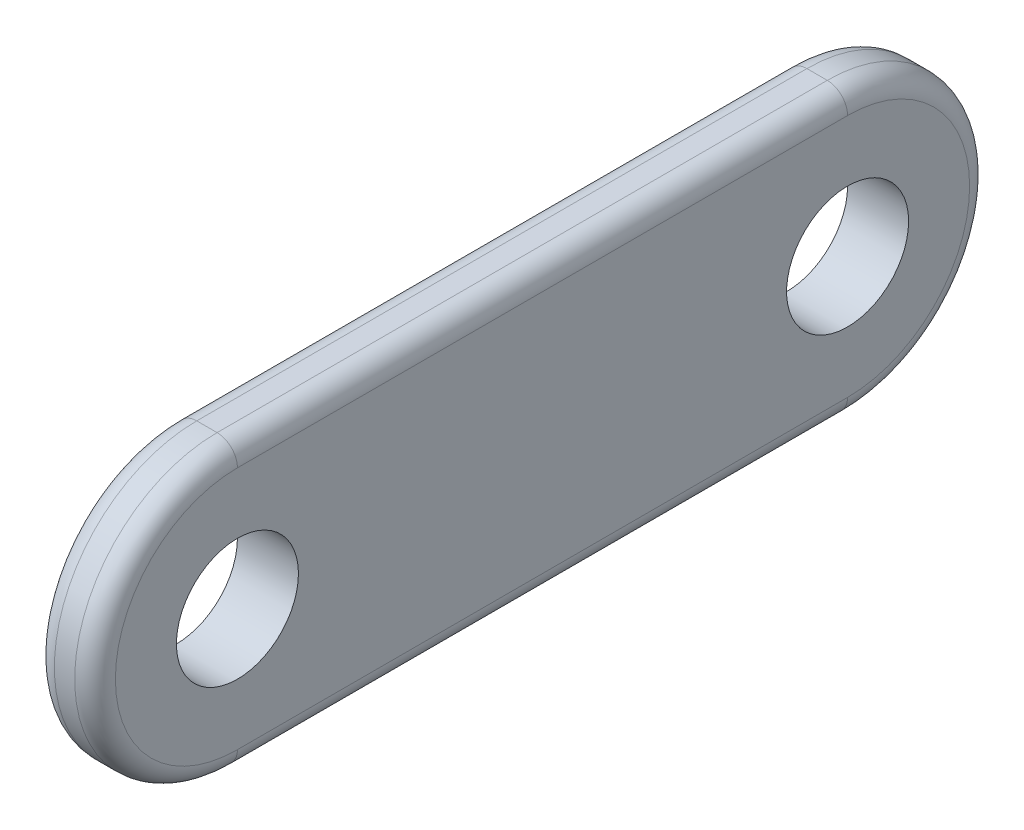
from build123d import *

# Parameters (mm, degrees)
SKETCH_1_R      = 3
EXTRUDE_1_DEPTH = 3
FILLET_1_R      = 1


with BuildPart() as part:
    # 草图1 → 凸台-拉伸1 (new body)
    with BuildSketch(Plane(origin=(0, 0, 0), x_dir=(0, 0, -1), z_dir=(1, 0, 0))):
        with BuildLine():
            Line((-15, 7), (15, 7))
            ThreePointArc((15, 7), (22, 0), (15, -7))
            Line((15, -7), (-15, -7))
            ThreePointArc((-15, -7), (-22, 0), (-15, 7))
        make_face()
        with Locations((-15, 0)):
            Circle(SKETCH_1_R, mode=Mode.SUBTRACT)
        with Locations((15, 0)):
            Circle(SKETCH_1_R, mode=Mode.SUBTRACT)
    extrude(amount=EXTRUDE_1_DEPTH)

    # 圆角1
    fillet_1_edges = [part.edges().sort_by_distance(p)[0] for p in [
        (3, 0, -22),
        (3, 7, 0),
        (3, 0, 22),
        (0, 7, 0),
        (0, 0, -22),
        (0, -7, 0),
        (0, 0, 22),
        (3, -7, 0),
    ]]
    fillet(fillet_1_edges, radius=FILLET_1_R)


solid = part.part
